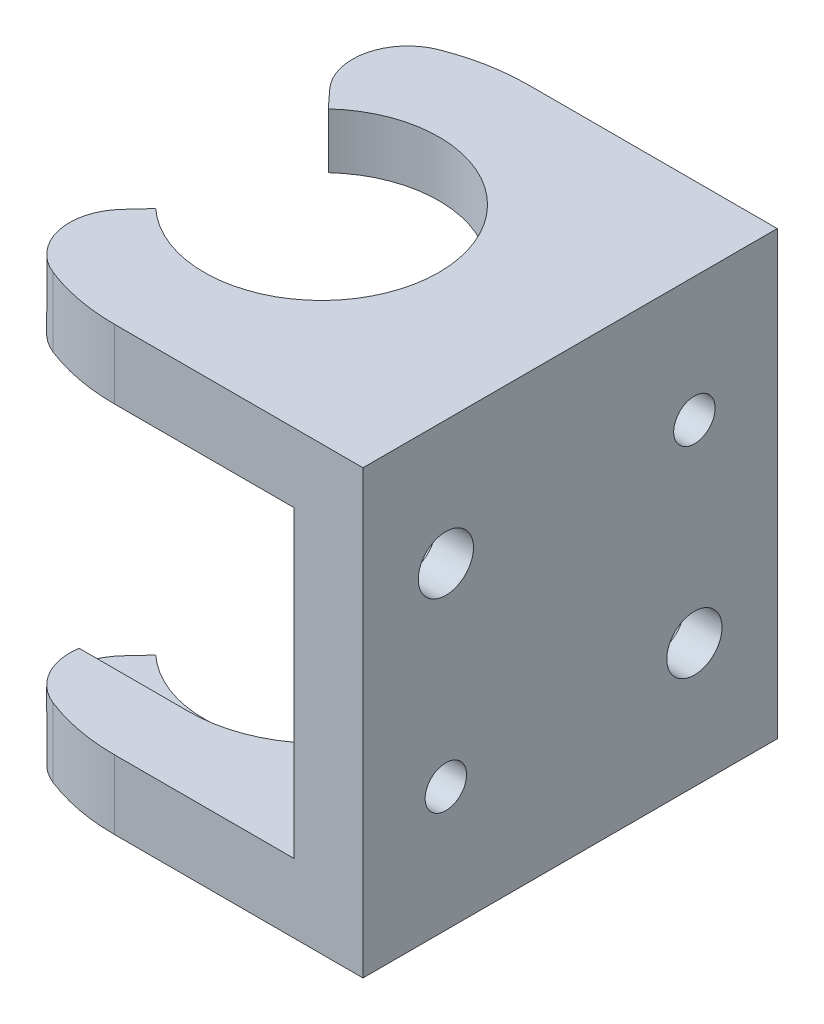
from build123d import *

# Parameters (mm, degrees)
BOSS_EXTRUDE1_DEPTH = 5
SKETCH3_W           = 5
SKETCH3_H           = 30
BOSS_EXTRUDE3_DEPTH = 22
BOSS_EXTRUDE4_DEPTH = 5
SKETCH5_R           = 1.5
SKETCH5_R_2         = 2
CUT_EXTRUDE1_DEPTH  = 29.166222313
FILLET1_R           = 4
CUT_EXTRUDE2_START  = -1
CUT_EXTRUDE2_DEPTH  = 24
CUT_EXTRUDE3_DEPTH  = 2.3


with BuildPart() as part:
    # Sketch2 → Boss-Extrude1 (new body)
    with BuildSketch(Plane(origin=(0, 0, 0), x_dir=(1, 0, 0), z_dir=(0, 1, 0))):
        with BuildLine():
            Line((18, -15), (18, 15))
            Line((18, 15), (0, 15))
            ThreePointArc((0, 15), (-5.457051563, 13.972136137), (-10.166222313, 11.029411765))
            Line((-10.166222313, 11.029411765), (-5.760859311, 6.25))
            ThreePointArc((-5.760859311, 6.25), (8.5, 0), (-5.760859311, -6.25))
            Line((-5.760859311, -6.25), (-10.166222313, -11.029411765))
            ThreePointArc((-10.166222313, -11.029411765), (-5.457051563, -13.972136137), (0, -15))
            Line((0, -15), (18, -15))
        make_face()
    extrude(amount=BOSS_EXTRUDE1_DEPTH)

    # Sketch3 → Boss-Extrude3 (add)
    with BuildSketch(Plane(origin=(0, 5, 0), x_dir=(1, 0, 0), z_dir=(0, 1, 0))):
        with Locations((15.5, 0)):
            Rectangle(SKETCH3_W, SKETCH3_H)
    extrude(amount=BOSS_EXTRUDE3_DEPTH)

    # Sketch4 → Boss-Extrude4 (add)
    with BuildSketch(Plane(origin=(0, 27, 0), x_dir=(1, 0, 0), z_dir=(0, 1, 0))):
        with BuildLine():
            Line((13, -15), (18, -15))
            Line((18, -15), (18, 15))
            Line((18, 15), (13, 15))
            Line((13, 15), (0, 15))
            ThreePointArc((0, 15), (-5.457051563, 13.972136137), (-10.166222313, 11.029411765))
            Line((-10.166222313, 11.029411765), (-5.760859311, 6.25))
            ThreePointArc((-5.760859311, 6.25), (8.5, 0), (-5.760859311, -6.25))
            Line((-5.760859311, -6.25), (-10.166222313, -11.029411765))
            ThreePointArc((-10.166222313, -11.029411765), (-5.457051563, -13.972136137), (0, -15))
            Line((0, -15), (13, -15))
        make_face()
    extrude(amount=BOSS_EXTRUDE4_DEPTH)

    # Sketch5 → Cut-Extrude1 (cut, through all)
    with BuildSketch(Plane(origin=(18, 0, 0), x_dir=(0, 0, -1), z_dir=(1, 0, 0))):
        with Locations((9, 23)):
            Circle(SKETCH5_R)
        with Locations((-9, 9)):
            Circle(SKETCH5_R)
        with Locations((-9, 23)):
            Circle(SKETCH5_R_2)
        with Locations((9, 9)):
            Circle(SKETCH5_R_2)
    extrude(amount=-CUT_EXTRUDE1_DEPTH, mode=Mode.SUBTRACT)

    # Fillet1
    fillet1_edges = [part.edges().sort_by_distance(p)[0] for p in [
        (-10.166222313, 2.5, 11.029411765),
        (-10.166222313, 2.5, -11.029411765),
        (-10.166222313, 29.5, 11.029411765),
        (-10.166222313, 29.5, -11.029411765),
    ]]
    fillet(fillet1_edges, radius=FILLET1_R)

    # Sketch6 → Cut-Extrude2 (cut)
    with BuildSketch(Plane.XZ.offset(-27).offset(CUT_EXTRUDE2_START)):
        with BuildLine():
            Line((-7.951245646, -9.6), (0, -9.6))
            ThreePointArc((0, -9.6), (-3.492513001, -8.942167128), (-6.506382281, -7.058823529))
            Line((-6.506382281, -7.058823529), (-6.944851968, -7.534522622))
            ThreePointArc((-6.944851968, -7.534522622), (-7.59954211, -8.493446945), (-7.951245646, -9.6))
        make_face()
        with BuildLine():
            ThreePointArc((9.6, 0), (6.788225099, 6.788225099), (0, 9.6))
            ThreePointArc((0, 9.6), (-3.492513001, 8.942167128), (-6.506382281, 7.058823529))
            Line((-6.506382281, 7.058823529), (-5.760859311, 6.25))
            ThreePointArc((-5.760859311, 6.25), (8.5, 0), (-5.760859311, -6.25))
            Line((-5.760859311, -6.25), (-6.506382281, -7.058823529))
            ThreePointArc((-6.506382281, -7.058823529), (-3.492513001, -8.942167128), (0, -9.6))
            ThreePointArc((0, -9.6), (6.788225099, -6.788225099), (9.6, 0))
        make_face()
        with BuildLine():
            Line((-5.760859311, 6.25), (-6.506382281, 7.058823529))
            ThreePointArc((-6.506382281, 7.058823529), (-8.792646641, 3.853487389), (-9.6, 0))
            ThreePointArc((-9.6, 0), (-8.792646641, -3.853487389), (-6.506382281, -7.058823529))
            Line((-6.506382281, -7.058823529), (-5.760859311, -6.25))
            ThreePointArc((-5.760859311, -6.25), (8.5, 0), (-5.760859311, 6.25))
        make_face()
        with BuildLine():
            ThreePointArc((-6.506382281, 7.058823529), (-3.492513001, 8.942167128), (0, 9.6))
            Line((0, 9.6), (-7.951245646, 9.6))
            ThreePointArc((-7.951245646, 9.6), (-7.59954211, 8.493446945), (-6.944851968, 7.534522622))
            Line((-6.944851968, 7.534522622), (-6.506382281, 7.058823529))
        make_face()
    extrude(amount=CUT_EXTRUDE2_DEPTH, mode=Mode.SUBTRACT)

    # Sketch7 → Cut-Extrude3 (cut)
    with BuildSketch(Plane.ZY.offset(-13)):
        Polygon((-4.958548116, 9), (-6.979274058, 12.5), (-11.020725942, 12.5), (-13.041451884, 9), (-11.020725942, 5.5), (-6.979274058, 5.5), align=None)
        Polygon((13.041451884, 23), (11.020725942, 26.5), (6.979274058, 26.5), (4.958548116, 23), (6.979274058, 19.5), (11.020725942, 19.5), align=None)
    extrude(amount=-CUT_EXTRUDE3_DEPTH, mode=Mode.SUBTRACT)


solid = part.part
